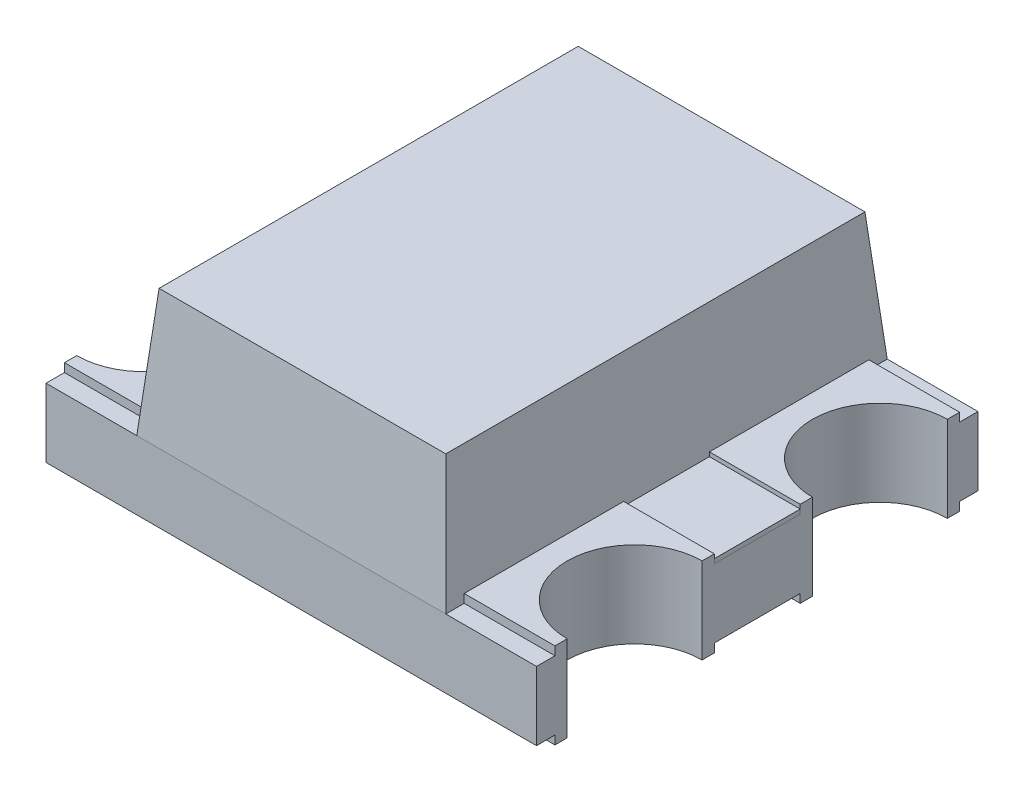
from build123d import *

# Parameters (mm, degrees)
SKETCH_1_W               = 2
SKETCH_1_H               = 1.8
EXTRUDE_1_DEPTH          = 0.28
EXTRUDE_3_DEPTH          = 0.018
SKETCH_8_W               = 0.53
SKETCH_8_H               = 0.65
EXTRUDE_4_DEPTH          = 0.035
SKETCH_9_W               = 0.37
SKETCH_9_H               = 0.65
EXTRUDE_5_DEPTH          = 0.035
SKETCH_2_R               = 0.275
CUT_EXTRUDE_2_DEPTH      = 1.035
CUT_EXTRUDE_2_DEPTH_BACK = 1.315
SKETCH_13_W              = 1.26
SKETCH_13_H              = 1.8
EXTRUDE_9_DEPTH          = 0.52
EXTRUDE_9_TAPER          = 5
SKETCH_14_W              = 0.37
SKETCH_14_H              = 0.35
EXTRUDE_10_DEPTH         = 0.018
EXTRUDE_11_DEPTH         = 0.035
EXTRUDE_11_2_DEPTH       = 0.035
SKETCH_16_W              = 0.49422098
SKETCH_16_H              = 0.305703699
EXTRUDE_12_DEPTH         = 0.1
SKETCH_16_W_2            = 0.120985562
SKETCH_16_H_2            = 0.147756788
EXTRUDE_12_2_DEPTH       = 0.1
SKETCH_16_W_3            = 0.105722529
SKETCH_16_H_3            = 0.15285185
EXTRUDE_12_3_DEPTH       = 0.1
SKETCH_16_W_4            = 0.252205552
SKETCH_16_H_4            = 0.132471603
EXTRUDE_12_4_DEPTH       = 0.1


with BuildPart() as part:
    # Эскиз1 → Бобышка-Вытянуть1 (new body)
    with BuildSketch(Plane(origin=(0, 0, 0), x_dir=(1, 0, 0), z_dir=(0, 1, 0))):
        Rectangle(SKETCH_1_W, SKETCH_1_H)
    extrude(amount=EXTRUDE_1_DEPTH)

    # Эскиз7 → Бобышка-Вытянуть3 (add)
    with BuildSketch(Plane.XZ):
        Polygon((0.36373067, 0), (-0.181865335, 0.315), (-0.181865335, -0.315), align=None)
    extrude(amount=EXTRUDE_3_DEPTH)

    # Эскиз8 → Бобышка-Вытянуть4 (add)
    with BuildSketch(Plane(origin=(0, 0, 0), x_dir=(-1, 0, 0), z_dir=(0, -1, 0))):
        with Locations((-0.735, -0.5)):
            Rectangle(SKETCH_8_W, SKETCH_8_H)
        with Locations((0.735, -0.5)):
            Rectangle(SKETCH_8_W, SKETCH_8_H)
        with Locations((-0.735, 0.5)):
            Rectangle(SKETCH_8_W, SKETCH_8_H)
        with Locations((0.735, 0.5)):
            Rectangle(SKETCH_8_W, SKETCH_8_H)
    extrude(amount=EXTRUDE_4_DEPTH)

    # Эскиз9 → Бобышка-Вытянуть5 (add)
    with BuildSketch(Plane(origin=(0, 0.28, 0), x_dir=(1, 0, 0), z_dir=(0, 1, 0))):
        with Locations((0.815, -0.5)):
            Rectangle(SKETCH_9_W, SKETCH_9_H)
        with Locations((0.815, 0.5)):
            Rectangle(SKETCH_9_W, SKETCH_9_H)
        with Locations((-0.815, -0.5)):
            Rectangle(SKETCH_9_W, SKETCH_9_H)
        with Locations((-0.815, 0.5)):
            Rectangle(SKETCH_9_W, SKETCH_9_H)
    extrude(amount=EXTRUDE_5_DEPTH)

    # Эскиз2 → Вырез-Вытянуть2 (cut, two sides)
    with BuildSketch(Plane(origin=(0, 0.28, 0), x_dir=(1, 0, 0), z_dir=(0, 1, 0))) as cut_extrude_2_sk:
        with Locations((1, 0.5)):
            Circle(SKETCH_2_R)
        with Locations((1, -0.5)):
            Circle(SKETCH_2_R)
        with Locations((-1, 0.5)):
            Circle(SKETCH_2_R)
        with Locations((-1, -0.5)):
            Circle(SKETCH_2_R)
    extrude(amount=CUT_EXTRUDE_2_DEPTH, mode=Mode.SUBTRACT)
    extrude(cut_extrude_2_sk.sketch, amount=-CUT_EXTRUDE_2_DEPTH_BACK, mode=Mode.SUBTRACT)


with BuildPart() as body_2:
    # Эскиз13 → Бобышка-Вытянуть9 (new body)
    with BuildSketch(Plane(origin=(0, 0.28, 0), x_dir=(1, 0, 0), z_dir=(0, 1, 0))):
        Rectangle(SKETCH_13_W, SKETCH_13_H)
    extrude(amount=EXTRUDE_9_DEPTH, taper=EXTRUDE_9_TAPER)


with BuildPart() as body_3:
    # Эскиз14 → Бобышка-Вытянуть10 (new body)
    with BuildSketch(Plane(origin=(0, 0.28, 0), x_dir=(1, 0, 0), z_dir=(0, 1, 0))):
        with Locations((0.815, 0)):
            Rectangle(SKETCH_14_W, SKETCH_14_H)
    extrude(amount=EXTRUDE_10_DEPTH)


with BuildPart() as body_4:
    # Эскиз15 → Бобышка-Вытянуть11 (new body)
    with BuildSketch(Plane(origin=(0, 0.28, 0), x_dir=(1, 0, 0), z_dir=(0, 1, 0))):
        with BuildLine():
            Line((-0.63, 0.419068821), (-0.47480357, 0.419068821))
            ThreePointArc((-0.47480357, 0.419068821), (-0.458754068, 0.422429859), (-0.445401716, 0.431948146))
            Line((-0.445401716, 0.431948146), (-0.196576052, 0.701703072))
            ThreePointArc((-0.196576052, 0.701703072), (-0.1832237, 0.711221358), (-0.167174198, 0.714582397))
            Line((-0.167174198, 0.714582397), (0.458042276, 0.714582397))
            ThreePointArc((0.458042276, 0.714582397), (0.486326548, 0.702866668), (0.498042276, 0.674582397))
            Line((0.498042276, 0.674582397), (0.498042276, 0.124815207))
            ThreePointArc((0.498042276, 0.124815207), (0.486326548, 0.096530936), (0.458042276, 0.084815207))
            Line((0.458042276, 0.084815207), (-0.417281783, 0.084815207))
            ThreePointArc((-0.417281783, 0.084815207), (-0.445566054, 0.096530936), (-0.457281783, 0.124815207))
            Line((-0.457281783, 0.124815207), (-0.457281783, 0.135))
            ThreePointArc((-0.457281783, 0.135), (-0.468997512, 0.163284271), (-0.497281783, 0.175))
            Line((-0.497281783, 0.175), (-0.63, 0.175))
            Line((-0.63, 0.175), (-0.63, 0.419068821))
        make_face()
    extrude(amount=EXTRUDE_11_DEPTH)


with BuildPart() as body_5:
    # Эскиз15 → Extrude 11 2 (new body)
    with BuildSketch(Plane(origin=(0, 0.28, 0), x_dir=(1, 0, 0), z_dir=(0, 1, 0))):
        with BuildLine():
            Line((-0.63, -0.175), (-0.333250558, -0.175))
            ThreePointArc((-0.333250558, -0.175), (-0.304966287, -0.186715729), (-0.293250558, -0.215))
            Line((-0.293250558, -0.215), (-0.293250558, -0.224389621))
            ThreePointArc((-0.293250558, -0.224389621), (-0.28153483, -0.252673893), (-0.253250558, -0.264389621))
            Line((-0.253250558, -0.264389621), (-0.172018831, -0.264389621))
            ThreePointArc((-0.172018831, -0.264389621), (-0.14373456, -0.252673893), (-0.132018831, -0.224389621))
            Line((-0.132018831, -0.224389621), (-0.132018831, -0.215))
            ThreePointArc((-0.132018831, -0.215), (-0.120303102, -0.186715729), (-0.092018831, -0.175))
            Line((-0.092018831, -0.175), (0.458042276, -0.175))
            ThreePointArc((0.458042276, -0.175), (0.486326548, -0.186715729), (0.498042276, -0.215))
            Line((0.498042276, -0.215), (0.498042276, -0.785))
            ThreePointArc((0.498042276, -0.785), (0.486326548, -0.813284271), (0.458042276, -0.825))
            Line((0.458042276, -0.825), (-0.63, -0.825))
            Line((-0.63, -0.825), (-0.63, -0.175))
        make_face()
    extrude(amount=EXTRUDE_11_2_DEPTH)


with BuildPart() as body_6:
    # Эскиз16 → Бобышка-Вытянуть12 (new body)
    with BuildSketch(Plane(origin=(0, 0.315, 0), x_dir=(1, 0, 0), z_dir=(0, 1, 0))):
        with Locations((0.182148454, 0.309524996)):
            Rectangle(SKETCH_16_W, SKETCH_16_H)
    extrude(amount=EXTRUDE_12_DEPTH)


with BuildPart() as body_7:
    # Эскиз16 → Extrude 12 2 (new body)
    with BuildSketch(Plane(origin=(0, 0.315, 0), x_dir=(1, 0, 0), z_dir=(0, 1, 0))):
        with Locations((-0.480857519, -0.299334872)):
            Rectangle(SKETCH_16_W_2, SKETCH_16_H_2)
    extrude(amount=EXTRUDE_12_2_DEPTH)


with BuildPart() as body_8:
    # Эскиз16 → Extrude 12 3 (new body)
    with BuildSketch(Plane(origin=(0, 0.315, 0), x_dir=(1, 0, 0), z_dir=(0, 1, 0))):
        with Locations((0.163595889, -0.299669803)):
            Rectangle(SKETCH_16_W_3, SKETCH_16_H_3)
    extrude(amount=EXTRUDE_12_3_DEPTH)


with BuildPart() as body_9:
    # Эскиз16 → Extrude 12 4 (new body)
    with BuildSketch(Plane(origin=(0, 0.315, 0), x_dir=(1, 0, 0), z_dir=(0, 1, 0))):
        with Locations((-0.189041788, -0.639404851)):
            Rectangle(SKETCH_16_W_4, SKETCH_16_H_4)
    extrude(amount=EXTRUDE_12_4_DEPTH)


solid = Compound([part.part, body_2.part, body_3.part, body_4.part, body_5.part, body_6.part, body_7.part, body_8.part, body_9.part])
